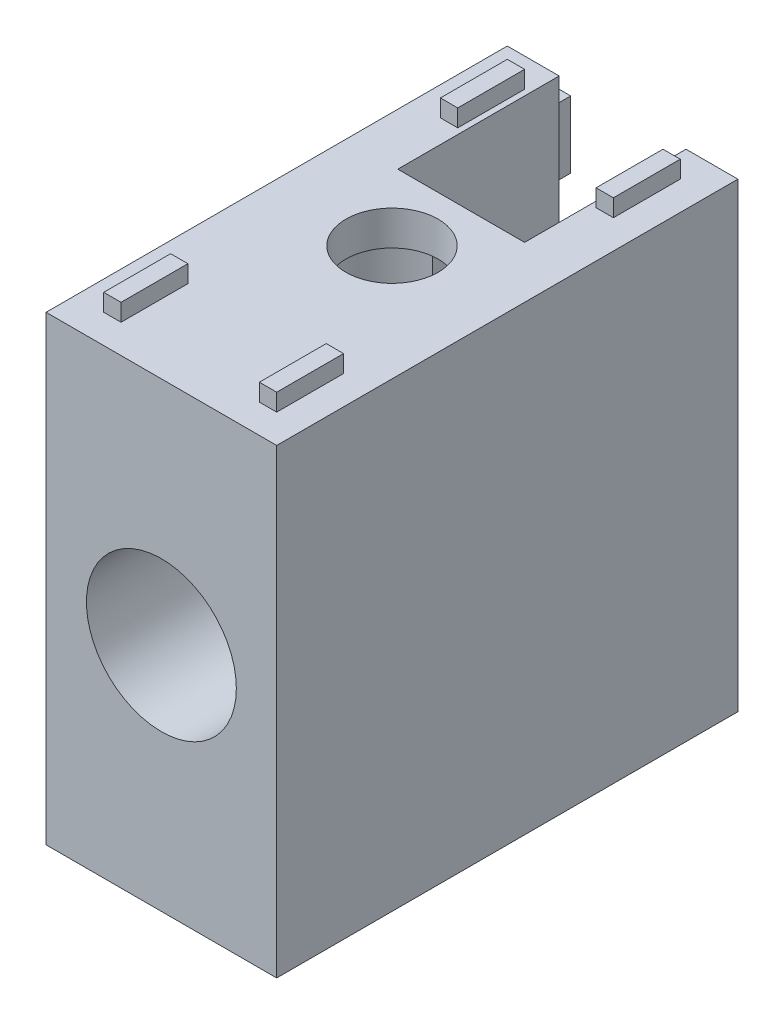
from build123d import *

# Parameters (mm, degrees)
SKETCH_2_W               = 40
SKETCH_2_H               = 40
EXTRUDE_2_DEPTH          = 10
SKETCH_4_W               = 1.5
SKETCH_4_H               = 5.8
EXTRUDE_3_DEPTH          = 1.5
SKETCH_5_W               = 14
SKETCH_5_H               = 14
CUT_EXTRUDE_1_DEPTH      = 5.5
CUT_EXTRUDE_1_DEPTH_BACK = 5.5


with BuildPart() as part:
    # Эскиз2 → Бобышка-Вытянуть2 (new body, symmetric)
    with BuildSketch(Plane(origin=(0, 0, 0), x_dir=(0, 0, -1), z_dir=(1, 0, 0))):
        Rectangle(SKETCH_2_W, SKETCH_2_H)
    extrude(amount=EXTRUDE_2_DEPTH, both=True)

    # Эскиз3 → Вырез-Повернуть1 (revolve, cut)
    with BuildSketch(Plane.XY, mode=Mode.PRIVATE) as cut_revolve_1_sk:
        Polygon((-4, 20), (-4, 17), (-6.5, 17), (-6.5, -20), (0, -20), (0, 20), align=None)
    cut_revolve_1 = revolve(cut_revolve_1_sk.sketch.rotate(Axis((0, -20, 0), (0, 1, 0)), 180), axis=Axis((0, -20, 0), (0, 1, 0)), mode=Mode.SUBTRACT)  # turned: the seam where the file's is

    # Эскиз4 → Бобышка-Вытянуть3 (add)
    with BuildSketch(Plane(origin=(0, 20, 0), x_dir=(1, 0, 0), z_dir=(0, 1, 0))):
        with Locations((-6.75, -14.6)):
            Rectangle(SKETCH_4_W, SKETCH_4_H)
        with Locations((-6.75, 14.6)):
            Rectangle(SKETCH_4_W, SKETCH_4_H)
        with Locations((6.75, 14.6)):
            Rectangle(SKETCH_4_W, SKETCH_4_H)
        with Locations((6.75, -14.6)):
            Rectangle(SKETCH_4_W, SKETCH_4_H)
    extrude_3 = extrude(amount=EXTRUDE_3_DEPTH)

    # Зеркальное отражение1: Вырез-Повернуть1, Бобышка-Вытянуть3 across plane
    add(cut_revolve_1.mirror(Plane(origin=(0, 0, 0), x_dir=(0, -0.707106781, 0.707106781), z_dir=(0, 0.707106781, 0.707106781))), mode=Mode.SUBTRACT)
    add(extrude_3.mirror(Plane(origin=(0, 0, 0), x_dir=(0, -0.707106781, 0.707106781), z_dir=(0, 0.707106781, 0.707106781))))

    # Эскиз5 → Вырез-Вытянуть1 (cut, two sides)
    with BuildSketch(Plane(origin=(0, 0, 0), x_dir=(0, 0, -1), z_dir=(1, 0, 0))) as cut_extrude_1_sk:
        with Locations((13, 13)):
            Rectangle(SKETCH_5_W, SKETCH_5_H)
    extrude(amount=CUT_EXTRUDE_1_DEPTH, mode=Mode.SUBTRACT)
    extrude(cut_extrude_1_sk.sketch, amount=-CUT_EXTRUDE_1_DEPTH_BACK, mode=Mode.SUBTRACT)


solid = part.part
